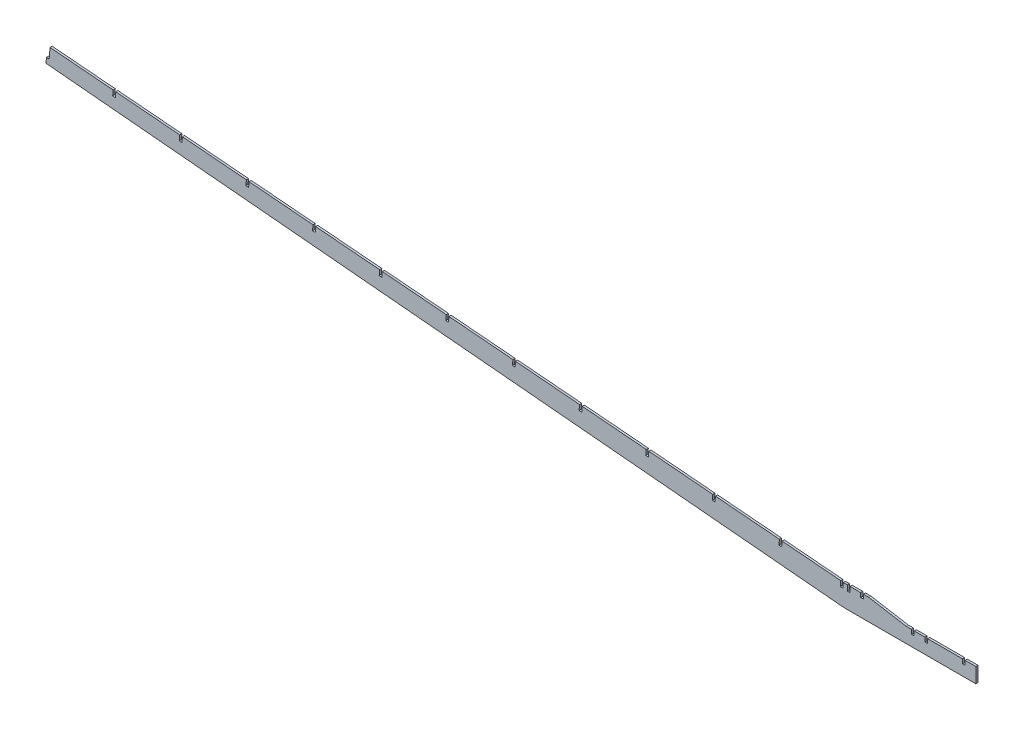
from build123d import *

# Parameters (mm, degrees)
BOSS_EXTRUDE1_DEPTH     = 2.54
CUT_EXTRUDE1_DEPTH      = 1
CUT_EXTRUDE1_DEPTH_BACK = 3.54


with BuildPart() as part:
    # Sketch1 → Boss-Extrude1 (new body)
    with BuildSketch(Plane.XY):
        Polygon((-945.957227657, 86.137779906), (-945.969713578, 86.1172966), (-949.121092485, 86.403457059), (-949.65244679, 80.075727402), (-9.887238192, -5.25964904), (-6.723373364, -5.525326193), (0, -5.833733414), (152.4, -5.833733414), (152.4, 11.946266586), (139.7, 11.946266586), (139.7, 6.866266586), (136.525, 6.866266586), (136.525, 11.946266586), (95.25, 11.946266586), (95.25, 6.866266586), (92.075, 6.866266586), (92.075, 11.946266586), (79.375, 11.946266586), (79.375, 6.866266586), (76.2, 6.866266586), (76.2, 11.946266586), (69.85, 11.946266586), (25.4, 19.566266586), (19.05, 19.566266586), (19.05, 14.486266586), (15.875, 14.486266586), (15.875, 19.566266586), (3.175, 19.566266586), (3.175, 13.216266586), (0, 13.216266586), (0, 19.566266586), (-1.98607431, 19.566266586), (-4.597956143, 19.785592432), (-5.129310448, 13.457862776), (-8.293175277, 13.723539928), (-7.761820971, 20.051269584), (-944.89858306, 98.744842179), align=None)
    extrude(amount=BOSS_EXTRUDE1_DEPTH)

    # Sketch2 → Cut-Extrude1 (cut, two sides)
    with BuildSketch(Plane.XY.offset(2.54)) as cut_extrude1_sk:
        Polygon((-77.240292597, 25.885539855), (-80.404157425, 26.151217008), (-80.935453586, 19.824179771), (-77.77159129, 19.55847246), align=None)
        Polygon((-156.741594191, 26.190526923), (-156.210358707, 32.516841584), (-159.374223535, 32.782518736), (-159.905456487, 26.456234233), align=None)
        Polygon((-235.711597092, 32.822581386), (-235.180424816, 39.148143312), (-238.344289645, 39.413820465), (-238.875459388, 33.088288696), align=None)
        Polygon((-314.681599993, 39.454635849), (-314.150490926, 45.77944504), (-317.314355754, 46.045122193), (-317.845462289, 39.720343159), align=None)
        Polygon((-393.651602894, 46.086690311), (-393.120557036, 52.410746769), (-396.284421864, 52.676423921), (-396.81546519, 46.352397622), align=None)
        Polygon((-472.621605795, 52.718744774), (-472.090623146, 59.042048497), (-475.254487974, 59.30772565), (-475.785468091, 52.984452084), align=None)
        Polygon((-551.591608696, 59.350799237), (-551.060689256, 65.673350226), (-554.224554084, 65.939027378), (-554.755470992, 59.616506547), align=None)
        Polygon((-630.561611597, 65.9828537), (-630.030755365, 72.304651954), (-633.194620194, 72.570329107), (-633.725473893, 66.24856101), align=None)
        Polygon((-709.531614498, 72.614908162), (-709.000821475, 78.935953682), (-712.164686303, 79.201630835), (-712.695476794, 72.880615473), align=None)
        Polygon((-788.501617399, 79.246962625), (-787.970887585, 85.567255411), (-791.134752413, 85.832932563), (-791.665479694, 79.512669935), align=None)
        Polygon((-867.4716203, 85.879017088), (-866.940953695, 92.198557139), (-870.104818523, 92.464234292), (-870.635482595, 86.144724398), align=None)
    extrude(amount=CUT_EXTRUDE1_DEPTH, mode=Mode.SUBTRACT)
    extrude(cut_extrude1_sk.sketch, amount=-CUT_EXTRUDE1_DEPTH_BACK, mode=Mode.SUBTRACT)


solid = part.part
